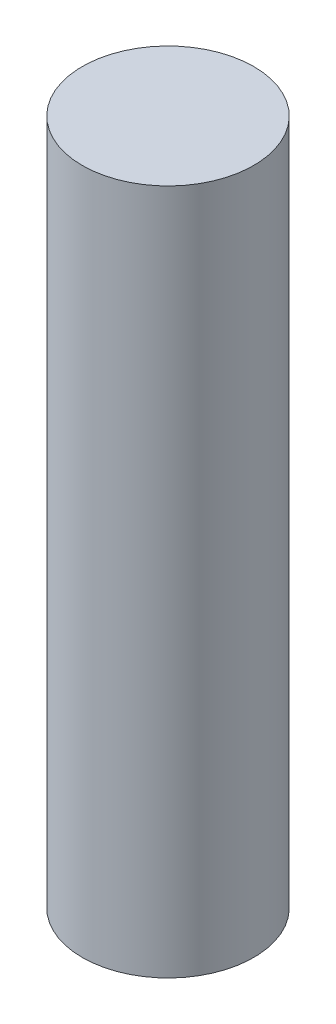
from build123d import *

# Parameters (mm, degrees)
SKETCH1_R           = 3.175
BOSS_EXTRUDE1_DEPTH = 25.4


with BuildPart() as part:
    # Sketch1 → Boss-Extrude1 (new body)
    with BuildSketch(Plane(origin=(0, 0, 0), x_dir=(1, 0, 0), z_dir=(0, 1, 0))):
        Circle(SKETCH1_R)
    extrude(amount=BOSS_EXTRUDE1_DEPTH)


solid = part.part
